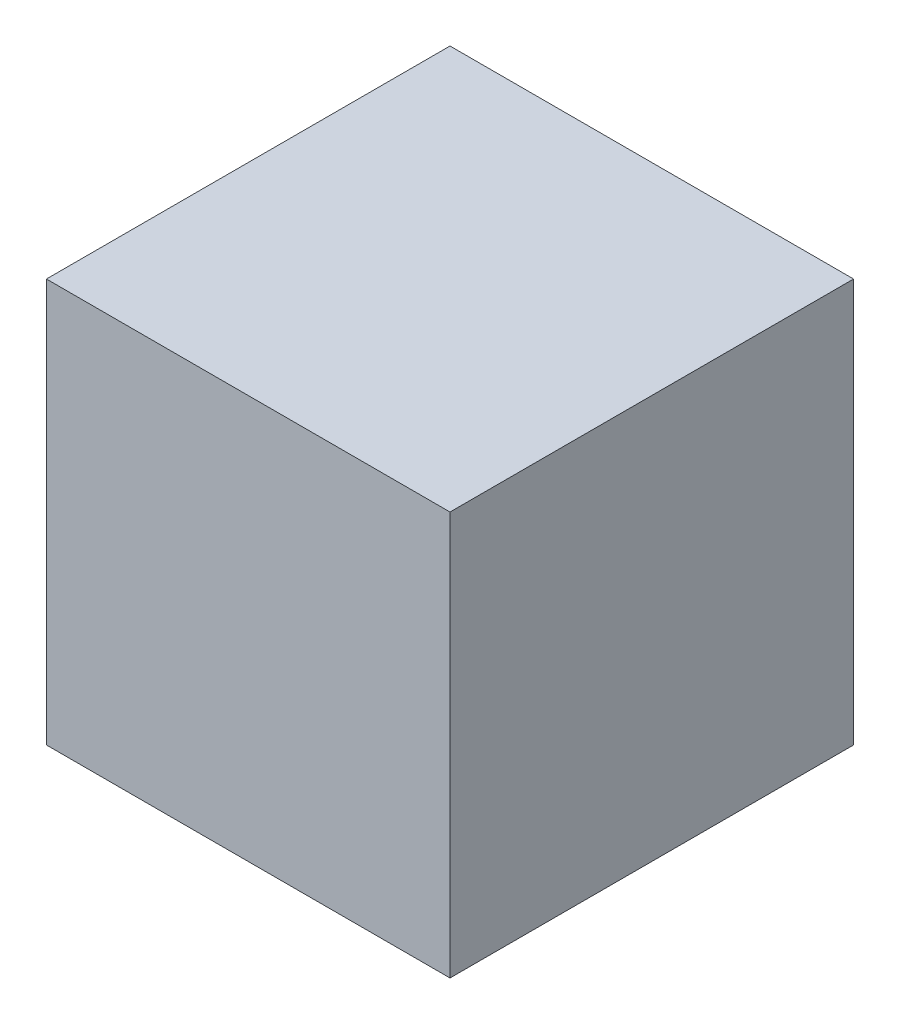
from build123d import *

# Parameters (mm, degrees)
SKETCH_1_W      = 30
SKETCH_1_H      = 30
EXTRUDE_1_DEPTH = 30


with BuildPart() as part:
    # 스케치1 → 보스-돌출1 (new body)
    with BuildSketch(Plane(origin=(0, 0, 0), x_dir=(1, 0, 0), z_dir=(0, 1, 0))):
        Rectangle(SKETCH_1_W, SKETCH_1_H)
    extrude(amount=EXTRUDE_1_DEPTH)

    # 스케치2 → 회전1 (revolve)
    with BuildSketch(Plane.XY):
        with BuildLine():
            Line((-17.5, 15), (-4.5, 15))
            ThreePointArc((-4.5, 15), (-11, 21.5), (-17.5, 15))
        make_face()
    revolve(axis=Axis((-17.5, 15, 0), (1, 0, 0)))


solid = part.part
